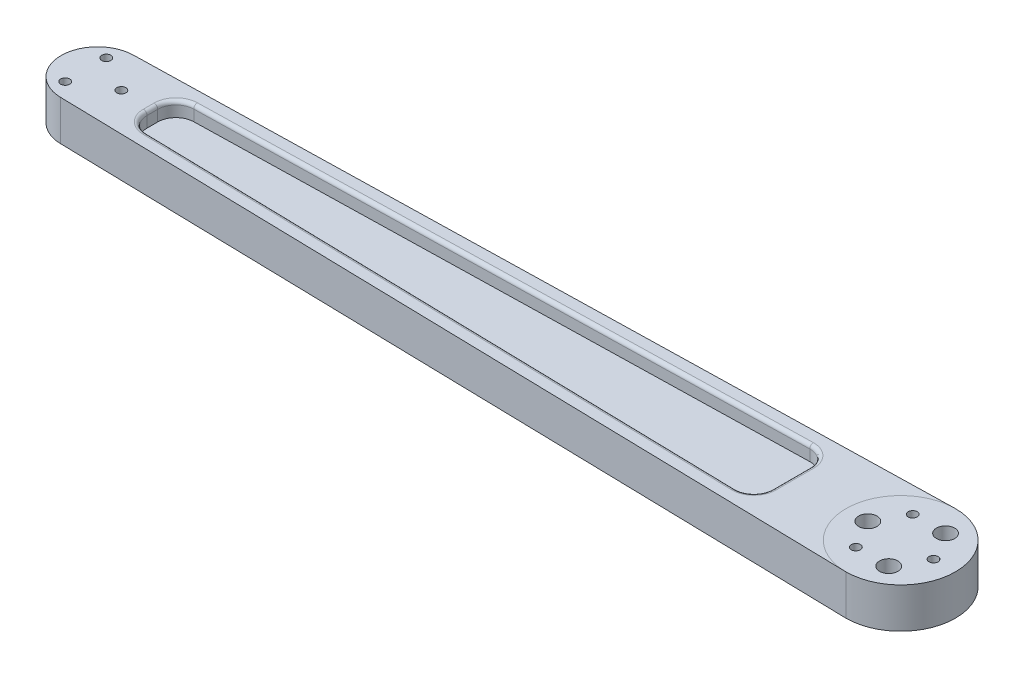
from build123d import *

# Parameters (mm, degrees)
EXTRUDE_2_DEPTH          = 11
HOLE_WIZARD_M3_1_D       = 2.5
PATTERN_CIRCULAR_2_COUNT = 3
HOLE_WIZARD_M3_2_D       = 2.5
PATTERN_CIRCULAR_4_COUNT = 3
F_5_0MM_2_D              = 5
PATTERN_CIRCULAR_5_COUNT = 3
CUT_EXTRUDE_1_DEPTH      = 4
FILLET_2_R               = 5
FILLET_4_R               = 5
FILLET_5_R               = 1
FILLET_6_R               = 1


with BuildPart() as part:
    # 스케치1 → 보스-돌출2 (new body)
    with BuildSketch(Plane(origin=(0, 0, 0), x_dir=(1, 0, 0), z_dir=(0, 1, 0))):
        with BuildLine():
            Line((0, -15), (-220.227083718, -9.998002197))
            ThreePointArc((-220.227083718, -9.998002197), (-230.000580731, 0), (-220.227083718, 9.998002197))
            Line((-220.227083718, 9.998002197), (0, 15))
            ThreePointArc((0, 15), (15, 0), (0, -15))
        make_face()
    extrude(amount=EXTRUDE_2_DEPTH)

    # M3 탭을 위한 탭 드릴1 (through all)
    with Locations(Plane(origin=(0, 11, 0), x_dir=(1, 0, 0), z_dir=(0, 1, 0))):
        with Locations((9, 0)):
            hole_wizard_m3_1 = Hole(HOLE_WIZARD_M3_1_D / 2)

    # 원형 패턴2: M3 탭을 위한 탭 드릴1 ×3 about axis
    pattern_circular_2_axis = Axis((0, 0, 0), (0, 1, 0))
    for i in range(1, PATTERN_CIRCULAR_2_COUNT):
        add(hole_wizard_m3_1.rotate(pattern_circular_2_axis, i * 360 / PATTERN_CIRCULAR_2_COUNT), mode=Mode.SUBTRACT)

    # M3 탭을 위한 탭 드릴2 (through all)
    with Locations(Plane(origin=(0, 11, 0), x_dir=(1, 0, 0), z_dir=(0, 1, 0))):
        with Locations((-213.5, 0)):
            hole_wizard_m3_2 = Hole(HOLE_WIZARD_M3_2_D / 2)

    # 원형 패턴4: M3 탭을 위한 탭 드릴2 ×3 about axis
    pattern_circular_4_axis = Axis((-220, 0, 0), (0, 1, 0))
    for i in range(1, PATTERN_CIRCULAR_4_COUNT):
        add(hole_wizard_m3_2.rotate(pattern_circular_4_axis, i * 360 / PATTERN_CIRCULAR_4_COUNT), mode=Mode.SUBTRACT)

    # Ø5.0mm 맞춤핀 구멍2 (through all)
    with Locations(Plane(origin=(0, 11, 0), x_dir=(1, 0, 0), z_dir=(0, 1, 0))):
        with Locations((-9, 0)):
            f_5_0mm_2 = Hole(F_5_0MM_2_D / 2)

    # 원형 패턴5: Ø5.0mm 맞춤핀 구멍2 ×3 about axis
    pattern_circular_5_axis = Axis((0, 0, 0), (0, 1, 0))
    for i in range(1, PATTERN_CIRCULAR_5_COUNT):
        add(f_5_0mm_2.rotate(pattern_circular_5_axis, i * 360 / PATTERN_CIRCULAR_5_COUNT), mode=Mode.SUBTRACT)

    # 스케치26 → 컷-돌출1 (cut)
    with BuildSketch(Plane(origin=(0, 11, 0), x_dir=(1, 0, 0), z_dir=(0, 1, 0))):
        Polygon((-30, 10.317581098), (-205, 6.342821951), (-205, -6.342821951), (-30, -10.317581098), align=None)
    cut_extrude_1 = extrude(amount=-CUT_EXTRUDE_1_DEPTH, mode=Mode.SUBTRACT)

    # 필렛2
    fillet_2_edges = [part.edges().sort_by_distance(p)[0] for p in [
        (-30, 9, -10.317581098),
        (-30, 9, 10.317581098),
        (-205, 9, 6.342821951),
        (-205, 9, -6.342821951),
    ]]
    fillet(fillet_2_edges, radius=FILLET_2_R)

    # 대칭 복사4: 컷-돌출1 across plane
    add(cut_extrude_1.mirror(Plane.ZX.offset(5.5)), mode=Mode.SUBTRACT)

    # 필렛4
    fillet_4_edges = [part.edges().sort_by_distance(p)[0] for p in [
        (-30, 2, 10.317581098),
        (-30, 2, -10.317581098),
        (-205, 2, -6.342821951),
        (-205, 2, 6.342821951),
    ]]
    fillet(fillet_4_edges, radius=FILLET_4_R)

    # 필렛5
    fillet_5_edges = [part.edges().sort_by_distance(p)[0] for p in [
        (-205, 0, 0),
        (-117.613535266, 0, 8.327622808),
        (-117.613535266, 0, -8.327622808),
        (-30, 0, 0),
        (-203.575449365, 0, 4.950259607),
        (-203.575449365, 0, -4.950259607),
        (-31.504837366, 0, 8.778176392),
        (-31.504837366, 0, -8.778176392),
    ]]
    fillet(fillet_5_edges, radius=FILLET_5_R)

    # 필렛6
    fillet_6_edges = [part.edges().sort_by_distance(p)[0] for p in [
        (-117.613535266, 11, 8.327622808),
        (-205, 11, 0),
        (-117.613535266, 11, -8.327622808),
        (-30, 11, 0),
        (-203.575449365, 11, 4.950259607),
        (-203.575449365, 11, -4.950259607),
        (-31.504837366, 11, 8.778176392),
        (-31.504837366, 11, -8.778176392),
    ]]
    fillet(fillet_6_edges, radius=FILLET_6_R)


solid = part.part
